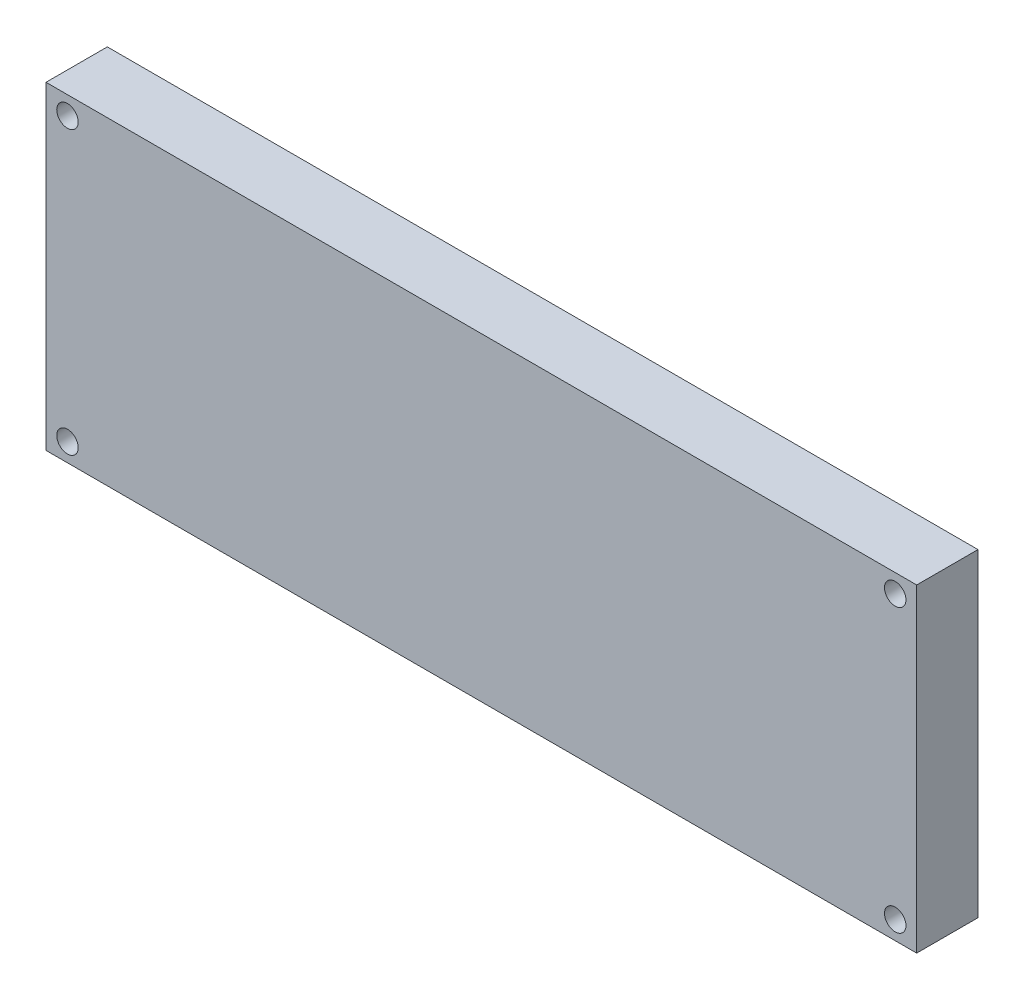
from build123d import *

# Parameters (mm, degrees)
SKETCH1_W           = 142
SKETCH1_H           = 52
SKETCH1_R           = 1.75
BOSS_EXTRUDE1_DEPTH = 10


with BuildPart() as part:
    # Sketch1 → Boss-Extrude1 (new body)
    with BuildSketch(Plane.XY):
        with Locations((71, 26)):
            Rectangle(SKETCH1_W, SKETCH1_H)
        with Locations((138.5, 49)):
            Circle(SKETCH1_R, mode=Mode.SUBTRACT)
        with Locations((3.5, 49)):
            Circle(SKETCH1_R, mode=Mode.SUBTRACT)
        with Locations((3.5, 3)):
            Circle(SKETCH1_R, mode=Mode.SUBTRACT)
        with Locations((138.5, 3)):
            Circle(SKETCH1_R, mode=Mode.SUBTRACT)
    extrude(amount=BOSS_EXTRUDE1_DEPTH)


solid = part.part
